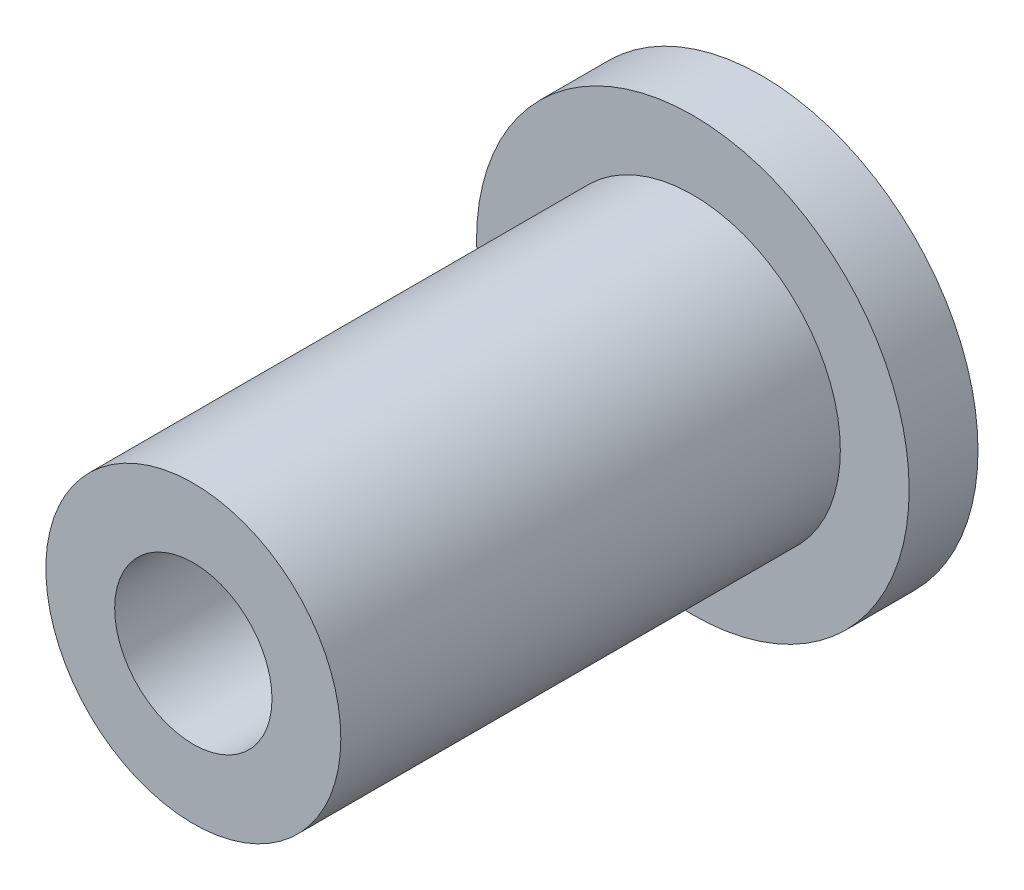
from build123d import *

# Parameters (mm, degrees)
SKETCH1_R    = 7.5
SKETCH1_R_2  = 4
INSERT_DEPTH = 12.7


with BuildPart() as part:
    # Sketch1 → Insert (new body, symmetric)
    with BuildSketch(Plane.XY):
        Circle(SKETCH1_R)
        Circle(SKETCH1_R_2, mode=Mode.SUBTRACT)
    extrude(amount=INSERT_DEPTH, both=True)

    # Sketch6 → Revolve5 (revolve)
    with BuildSketch(Plane(origin=(0, 0, 0), x_dir=(1, 0, 0), z_dir=(0, 1, 0))):
        Polygon((-11, 16.2), (-11, 12.7), (-7.5, 12.7), (-4, 12.7), (-4, 16.2), (-7.5, 16.2), align=None)
    revolve(axis=Axis((0, 0, -17.177869937), (0, 0, 1)))


solid = part.part
